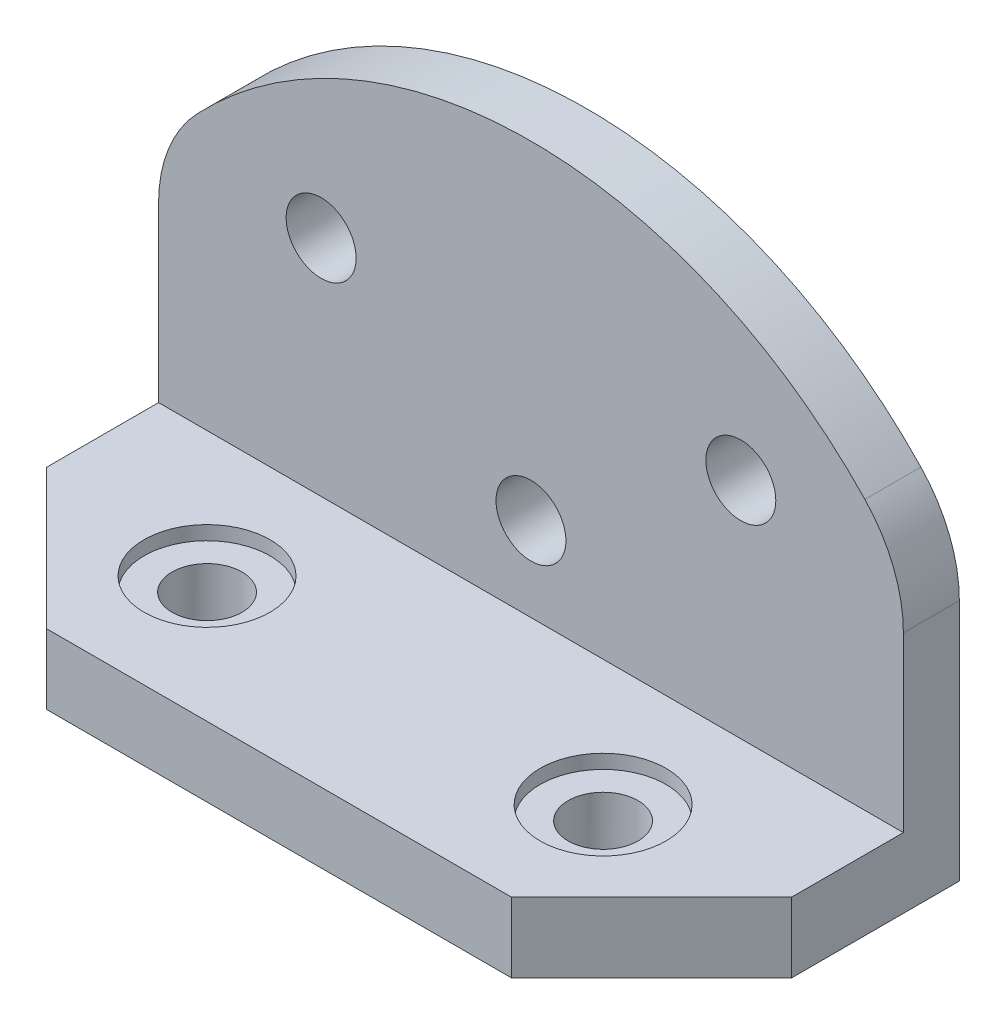
from build123d import *

# Parameters (mm, degrees)
SKETCH1_R           = 1.25
BOSS_EXTRUDE1_DEPTH = 2
SKETCH2_W           = 26.619471542
SKETCH2_H           = 2.5
BOSS_EXTRUDE2_DEPTH = 9
SKETCH3_R           = 1.25
CUT_EXTRUDE1_DEPTH  = 9
SKETCH4_R           = 2.25
CUT_EXTRUDE2_DEPTH  = 0.5
CHAMFER1_SIZE       = 5


with BuildPart() as part:
    # Sketch1 → Boss-Extrude1 (new body)
    with BuildSketch(Plane.XY):
        with BuildLine():
            Line((-13.309735771, 0.225207445), (13.309735771, 0.225207445))
            Line((13.309735771, 0.225207445), (13.309735771, 8.907396156))
            ThreePointArc((13.309735771, 8.907396156), (12.953344247, 10.761284051), (11.934975641, 12.350887972))
            ThreePointArc((11.934975641, 12.350887972), (0, 17.475207445), (-11.934975641, 12.350887972))
            ThreePointArc((-11.934975641, 12.350887972), (-12.953344247, 10.761284051), (-13.309735771, 8.907396156))
            Line((-13.309735771, 8.907396156), (-13.309735771, 0.225207445))
        make_face()
        with Locations((7.499735771, 10.725207445)):
            Circle(SKETCH1_R, mode=Mode.SUBTRACT)
        with Locations((-7.500264229, 10.725207445)):
            Circle(SKETCH1_R, mode=Mode.SUBTRACT)
        with Locations((-0.000264229, 5.725207445)):
            Circle(SKETCH1_R, mode=Mode.SUBTRACT)
    extrude(amount=BOSS_EXTRUDE1_DEPTH)

    # Sketch2 → Boss-Extrude2 (add)
    with BuildSketch(Plane.XY.offset(2)):
        with Locations((0, 1.475207445)):
            Rectangle(SKETCH2_W, SKETCH2_H)
    extrude(amount=BOSS_EXTRUDE2_DEPTH)

    # Sketch3 → Cut-Extrude1 (cut)
    with BuildSketch(Plane(origin=(0, 2.725207445, 0), x_dir=(1, 0, 0), z_dir=(0, 1, 0))):
        with Locations(Location((-7.077404832, -6.5, 0), (0, 0, 270))):  # turned: the seam where the file's is
            Circle(SKETCH3_R)
        with Locations(Location((7.077404832, -6.5, 0), (0, 0, 270))):  # turned: the seam where the file's is
            Circle(SKETCH3_R)
    extrude(amount=-CUT_EXTRUDE1_DEPTH, mode=Mode.SUBTRACT)

    # Sketch4 → Cut-Extrude2 (cut)
    with BuildSketch(Plane(origin=(0, 2.725207445, 0), x_dir=(1, 0, 0), z_dir=(0, 1, 0))):
        with Locations(Location((-7.077404832, -6.5, 0), (0, 0, 270))):  # turned: the seam where the file's is
            Circle(SKETCH4_R)
        with Locations(Location((7.077404832, -6.5, 0), (0, 0, 270))):  # turned: the seam where the file's is
            Circle(SKETCH4_R)
    extrude(amount=-CUT_EXTRUDE2_DEPTH, mode=Mode.SUBTRACT)

    # Chamfer1
    chamfer1_edges = [part.edges().sort_by_distance(p)[0] for p in [
        (13.309735771, 1.475207445, 11),
        (-13.309735771, 1.475207445, 11),
    ]]
    chamfer(chamfer1_edges, length=CHAMFER1_SIZE)


solid = part.part
